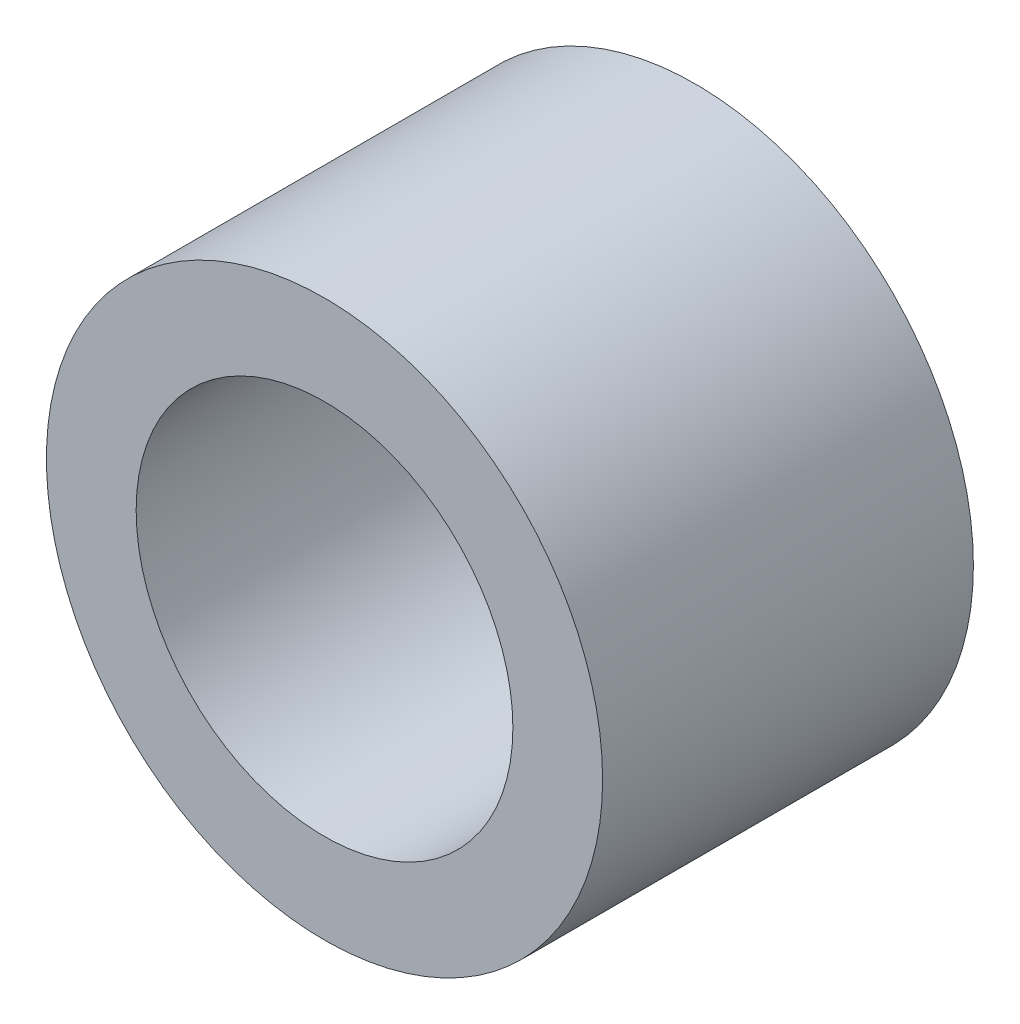
from build123d import *

# Parameters (mm, degrees)
SKETCH1_R      = 4.7625
SKETCH1_R_2    = 3.2258
EXTRUDE1_DEPTH = 3.175


with BuildPart() as part:
    # Sketch1 → Extrude1 (new body, symmetric)
    with BuildSketch(Plane.XY):
        Circle(SKETCH1_R)
        Circle(SKETCH1_R_2, mode=Mode.SUBTRACT)
    extrude(amount=EXTRUDE1_DEPTH, both=True)


solid = part.part
